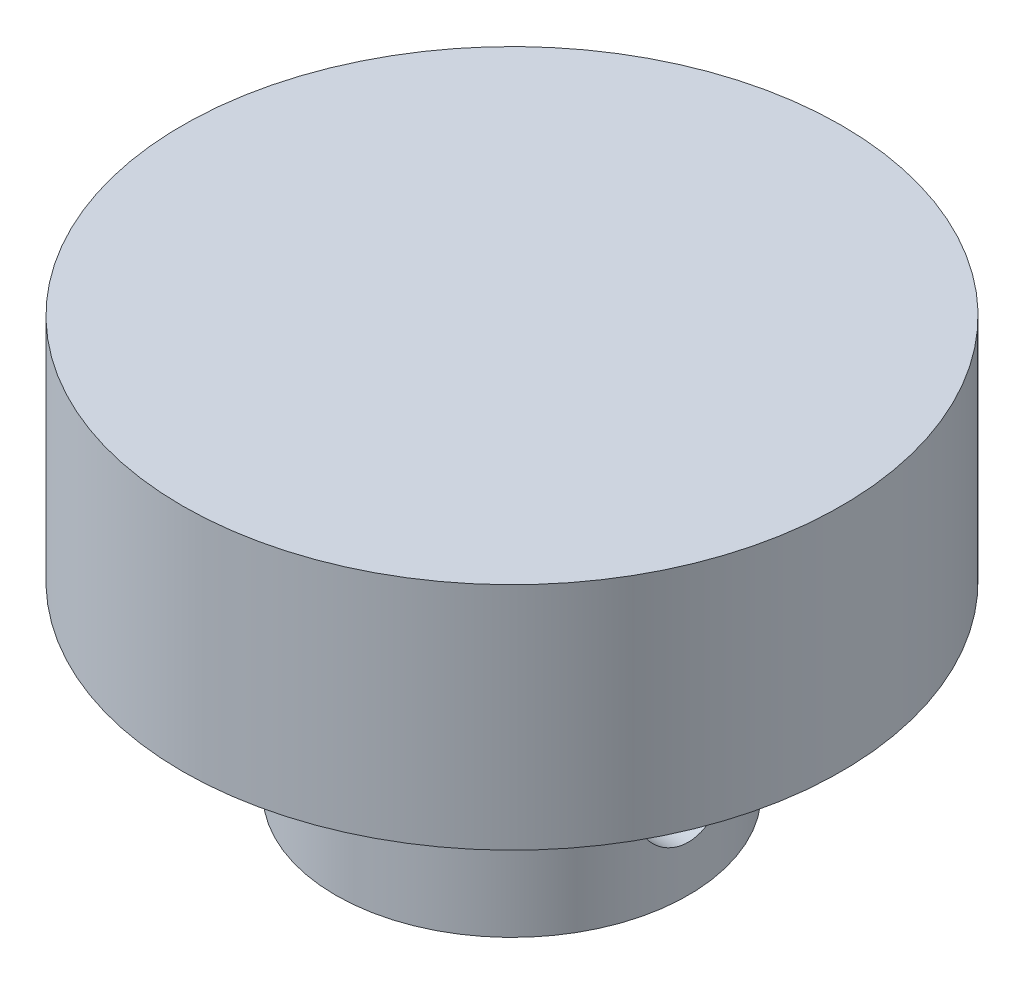
from build123d import *

# Parameters (mm, degrees)
SKETCH4_R               = 3
CUT_EXTRUDE2_DEPTH      = 15
CUT_EXTRUDE2_DEPTH_BACK = 13


with BuildPart() as part:
    # Sketch1 → Revolve1 (revolve)
    with BuildSketch(Plane(origin=(0, 0, 0), x_dir=(0, 0, -1), z_dir=(1, 0, 0))):
        Polygon((2, 0), (21.5, 0), (21.5, -15), (11.5, -15), (11.5, -27), (2, -27), (2, -15), (0, -15), (0, 0), align=None)
    revolve(axis=Axis((0, 0, 0), (0, 1, 0)))

    # Sketch4 → Cut-Extrude2 (cut, two sides)
    with BuildSketch(Plane(origin=(0, 0, 0), x_dir=(0, 0, -1), z_dir=(1, 0, 0))) as cut_extrude2_sk:
        with Locations((0, -21)):
            Circle(SKETCH4_R)
    extrude(amount=CUT_EXTRUDE2_DEPTH, mode=Mode.SUBTRACT)
    extrude(cut_extrude2_sk.sketch, amount=-CUT_EXTRUDE2_DEPTH_BACK, mode=Mode.SUBTRACT)


solid = part.part
